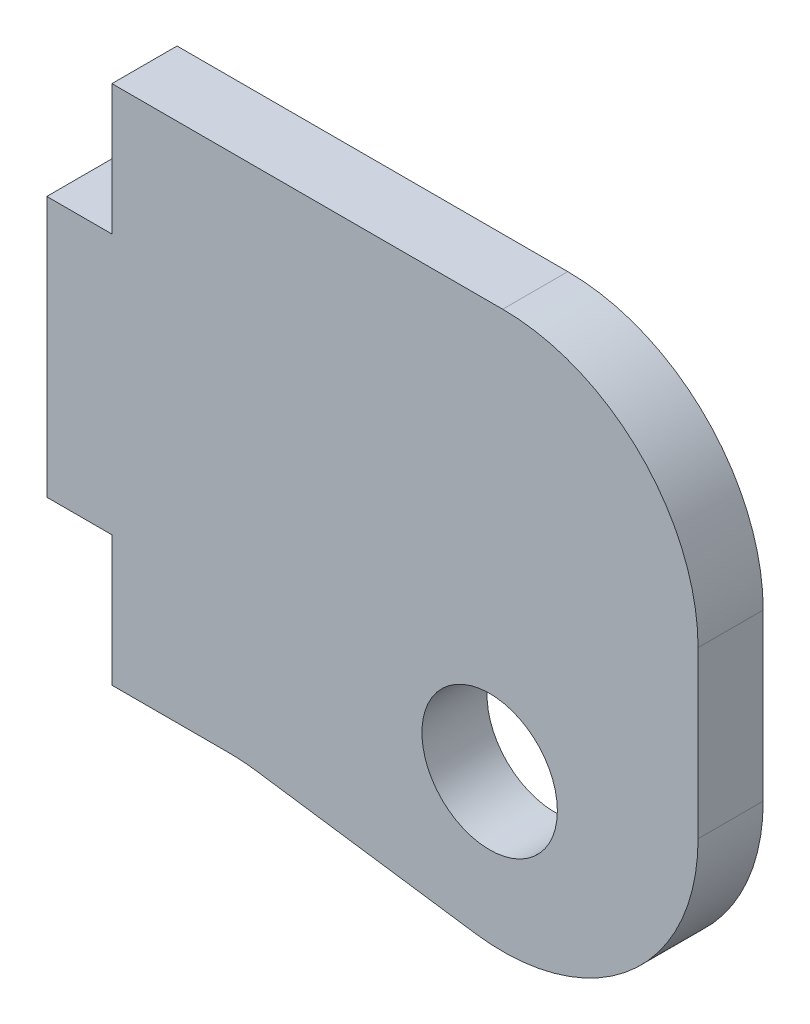
from build123d import *

# Parameters (mm, degrees)
BOSS_EXTRUDE1_DEPTH = 3.175
SKETCH2_R           = 3.302
CUT_EXTRUDE1_DEPTH  = 3.175
FILLET1_R           = 9.525
SKETCH3_W           = 3.175
SKETCH3_H           = 6.35
CUT_EXTRUDE2_DEPTH  = 3.175


with BuildPart() as part:
    # Sketch1 → Boss-Extrude1 (new body)
    with BuildSketch(Plane.XY):
        Polygon((0, 12.7), (0, -12.7), (9.525, -12.7), (31.75, -15.875), (31.75, 12.7), align=None)
    extrude(amount=BOSS_EXTRUDE1_DEPTH)

    # Sketch2 → Cut-Extrude1 (cut)
    with BuildSketch(Plane.XY.offset(3.175)):
        with Locations((21.588299978, -7.140871599)):
            Circle(SKETCH2_R)
    extrude(amount=-CUT_EXTRUDE1_DEPTH, mode=Mode.SUBTRACT)

    # Fillet1
    fillet1_edges = [part.edges().sort_by_distance(p)[0] for p in [
        (31.75, 12.7, 1.5875),
        (31.75, -15.875, 1.5875),
        (9.525, -12.7, 1.5875),
    ]]
    fillet(fillet1_edges, radius=FILLET1_R)

    # Sketch3 → Cut-Extrude2 (cut)
    with BuildSketch(Plane.XY.offset(3.175)):
        with Locations((1.5875, -9.525)):
            Rectangle(SKETCH3_W, SKETCH3_H)
        with Locations((1.5875, 9.525)):
            Rectangle(SKETCH3_W, SKETCH3_H)
    extrude(amount=-CUT_EXTRUDE2_DEPTH, mode=Mode.SUBTRACT)


solid = part.part
